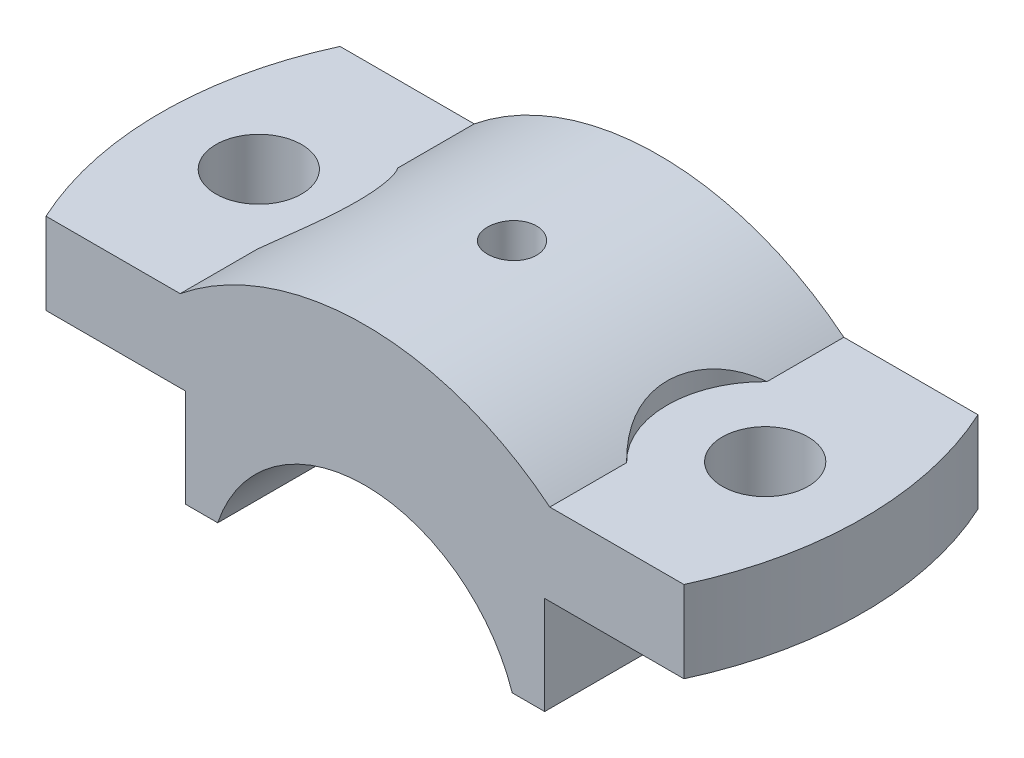
from build123d import *

# Parameters (mm, degrees)
BOSS_EXTRUDE1_DEPTH = 36
CUT_EXTRUDE1_DEPTH  = 10
CUT_EXTRUDE2_DEPTH  = 10
CUT_EXTRUDE8_DEPTH  = 10
SKETCH9_R           = 5.25
CUT_EXTRUDE9_DEPTH  = 10
CUT_EXTRUDE10_DEPTH = 10
SKETCH11_R          = 3
CUT_EXTRUDE11_DEPTH = 10
SKETCH13_R          = 1.5
CUT_EXTRUDE12_DEPTH = 10
FILLET2_R           = 1


with BuildPart() as part:
    # Sketch1 → Boss-Extrude1 (new body)
    with BuildSketch(Plane.XY):
        with BuildLine():
            Line((-22.627416998, 20.226289935), (-43, 20.226289935))
            Line((-43, 20.226289935), (-43, 10.226289935))
            Line((-43, 10.226289935), (-22, 10.226289935))
            Line((-22, 10.226289935), (-22, -1.773710065))
            Line((-22, -1.773710065), (-18.027756377, -1.773710065))
            ThreePointArc((-18.027756377, -1.773710065), (0, 11.226289935), (18.027756377, -1.773710065))
            Line((18.027756377, -1.773710065), (22, -1.773710065))
            Line((22, -1.773710065), (22, 10.226289935))
            Line((22, 10.226289935), (43, 10.226289935))
            Line((43, 10.226289935), (43, 20.226289935))
            Line((43, 20.226289935), (22.627416998, 20.226289935))
            ThreePointArc((22.627416998, 20.226289935), (0, 28.226289935), (-22.627416998, 20.226289935))
        make_face()
    extrude(amount=BOSS_EXTRUDE1_DEPTH)

    # Sketch3 → Cut-Extrude1 (cut)
    with BuildSketch(Plane(origin=(0, 20.226289935, 0), x_dir=(1, 0, 0), z_dir=(0, 1, 0))):
        with BuildLine():
            ThreePointArc((-43, -18), (-42.001212365, -8.785980256), (-39.05124838, 0))
            Line((-39.05124838, 0), (-43, 0))
            Line((-43, 0), (-43, -18))
        make_face()
    extrude(amount=-CUT_EXTRUDE1_DEPTH, mode=Mode.SUBTRACT)

    # Sketch4 → Cut-Extrude2 (cut)
    with BuildSketch(Plane(origin=(0, 20.226289935, 0), x_dir=(1, 0, 0), z_dir=(0, 1, 0))):
        with BuildLine():
            ThreePointArc((-39.05124838, -36), (-42.001212365, -27.214019744), (-43, -18))
            Line((-43, -18), (-43, -36))
            Line((-43, -36), (-39.05124838, -36))
        make_face()
    extrude(amount=-CUT_EXTRUDE2_DEPTH, mode=Mode.SUBTRACT)

    # Sketch5 → Cut-Extrude8 (cut)
    with BuildSketch(Plane(origin=(0, 20.226289935, 0), x_dir=(1, 0, 0), z_dir=(0, 1, 0))):
        with BuildLine():
            Line((43, -36), (43, -18))
            ThreePointArc((43, -18), (42.001212365, -27.214019744), (39.05124838, -36))
            Line((39.05124838, -36), (43, -36))
        make_face()
        with BuildLine():
            ThreePointArc((39.05124838, 0), (42.001212365, -8.785980256), (43, -18))
            Line((43, -18), (43, 0))
            Line((43, 0), (39.05124838, 0))
        make_face()
    extrude(amount=-CUT_EXTRUDE8_DEPTH, mode=Mode.SUBTRACT)

    # Sketch9 → Cut-Extrude9 (cut)
    with BuildSketch(Plane(origin=(0, 20.226289935, 0), x_dir=(1, 0, 0), z_dir=(0, 1, 0))):
        with Locations((31, -18)):
            Circle(SKETCH9_R)
        with Locations((-31, -18)):
            Circle(SKETCH9_R)
    extrude(amount=-CUT_EXTRUDE9_DEPTH, mode=Mode.SUBTRACT)

    # Sketch10 → Cut-Extrude10 (cut)
    with BuildSketch(Plane(origin=(0, 20.226289935, 0), x_dir=(1, 0, 0), z_dir=(0, 1, 0))):
        with BuildLine():
            Line((22.627416998, -9.403497579), (22.627416998, -26.596502421))
            ThreePointArc((22.627416998, -26.596502421), (19, -18), (22.627416998, -9.403497579))
        make_face()
        with BuildLine():
            Line((-22.627416998, -9.403497579), (-22.627416998, -26.596502421))
            ThreePointArc((-22.627416998, -26.596502421), (-19, -18), (-22.627416998, -9.403497579))
        make_face()
    extrude(amount=CUT_EXTRUDE10_DEPTH, mode=Mode.SUBTRACT)

    # Sketch11 → Cut-Extrude11 (cut)
    with BuildSketch(Plane(origin=(0, 28.226289935, 0), x_dir=(1, 0, 0), z_dir=(0, 1, 0))):
        with Locations((0, -18)):
            Circle(SKETCH11_R)
    extrude(amount=-CUT_EXTRUDE11_DEPTH, mode=Mode.SUBTRACT)

    # Sketch13 → Cut-Extrude12 (cut)
    with BuildSketch(Plane(origin=(0, 18.226289935, 0), x_dir=(1, 0, 0), z_dir=(0, 1, 0))):
        with Locations((0, -18)):
            Circle(SKETCH13_R)
    extrude(amount=-CUT_EXTRUDE12_DEPTH, mode=Mode.SUBTRACT)

    # Fillet2
    fillet2_edges = [part.edges().sort_by_distance(p)[0] for p in [
        (-3, 18.226289935, 18),
    ]]
    fillet(fillet2_edges, radius=FILLET2_R)


solid = part.part
